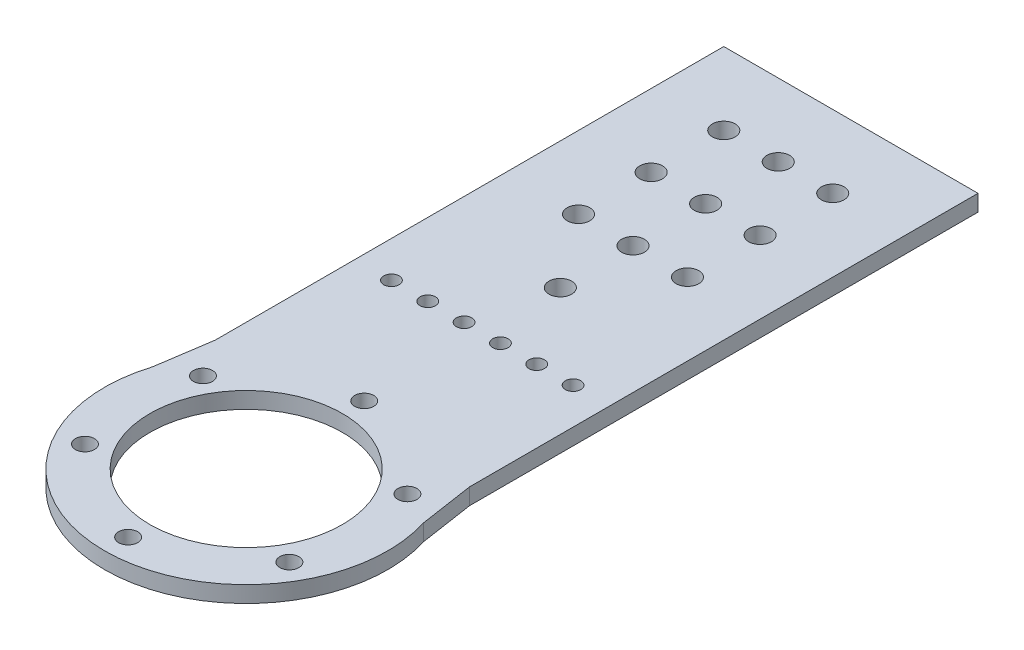
from build123d import *

# Parameters (mm, degrees)
SKETCH1_R               = 39
SKETCH1_R_2             = 26.5
BOSS_EXTRUDE1_DEPTH     = 2.25
SKETCH3_W               = 50
SKETCH3_H               = 51.5
BOSS_EXTRUDE2_DEPTH     = 2.25
BOSS_EXTRUDE4_DEPTH     = 2.25
SKETCH2_R               = 2.625
CUT_EXTRUDE1_DEPTH      = 3.25
CIRPATTERN1_COUNT       = 6
CUT_EXTRUDE3_START      = -5.5
SKETCH7_R               = 3.125
CUT_EXTRUDE3_DEPTH      = 6.5
LPATTERN3_COUNT         = 3
LPATTERN3_PITCH         = 20
SKETCH8_R               = 3.125
CUT_EXTRUDE4_DEPTH      = 10
LPATTERN4_COUNT         = 4
LPATTERN4_PITCH         = 20
CUT_EXTRUDE5_START      = -5.5
SKETCH9_R               = 2.125
CUT_EXTRUDE5_DEPTH      = 6.5
LPATTERN5_COUNT         = 3
LPATTERN5_PITCH         = 10
MIRROR1_START           = -5.5
MIRROR1_COPY_1_SKETCH_R = 2.125
MIRROR1_COPY_1_DEPTH    = 6.5
MIRROR1_COPY_2_SKETCH_R = 2.125
MIRROR1_COPY_2_DEPTH    = 6.5


with BuildPart() as part:
    # Sketch1 → Boss-Extrude1 (new body, symmetric)
    with BuildSketch(Plane(origin=(0, 0, 0), x_dir=(1, 0, 0), z_dir=(0, 1, 0))):
        Circle(SKETCH1_R)
        Circle(SKETCH1_R_2, mode=Mode.SUBTRACT)
    extrude(amount=BOSS_EXTRUDE1_DEPTH, both=True)

    # Sketch3 → Boss-Extrude2 (add, symmetric)
    with BuildSketch(Plane(origin=(0, 0, 0), x_dir=(1, 0, 0), z_dir=(0, 1, 0))):
        with Locations((0, 52.25)):
            Rectangle(SKETCH3_W, SKETCH3_H)
    extrude(amount=BOSS_EXTRUDE2_DEPTH, both=True)

    # Sketch6 → Boss-Extrude4 (add, symmetric)
    with BuildSketch(Plane(origin=(0, 0, 0), x_dir=(1, 0, 0), z_dir=(0, 1, 0))):
        Polygon((-35, 166.5), (-35, 26.5), (-39, 0), (-14.981514186, 26.5), (16.520833333, 26.5), (39, 0), (35, 26.5), (35, 166.5), align=None)
    extrude(amount=BOSS_EXTRUDE4_DEPTH, both=True)

    # Sketch2 → Cut-Extrude1 (cut, symmetric)
    with BuildSketch(Plane(origin=(0, 0, 0), x_dir=(1, 0, 0), z_dir=(0, 1, 0))):
        with Locations((0, 32.5)):
            Circle(SKETCH2_R)
    cut_extrude1 = extrude(amount=CUT_EXTRUDE1_DEPTH, both=True, mode=Mode.SUBTRACT)

    # CirPattern1: Cut-Extrude1 ×6 about axis
    cirpattern1_axis = Axis((0, 0, 0), (0, 1, 0))
    for i in range(1, CIRPATTERN1_COUNT):
        add(cut_extrude1.rotate(cirpattern1_axis, i * 360 / CIRPATTERN1_COUNT), mode=Mode.SUBTRACT)

    # Sketch7 → Cut-Extrude3 (cut)
    with BuildSketch(Plane(origin=(0, 2.25, 0), x_dir=(1, 0, 0), z_dir=(0, 1, 0)).offset(CUT_EXTRUDE3_START)):
        with Locations((-15, 146.5)):
            Circle(SKETCH7_R)
        with Locations((15, 146.5)):
            Circle(SKETCH7_R)
    cut_extrude3 = extrude(amount=CUT_EXTRUDE3_DEPTH, mode=Mode.SUBTRACT)

    # LPattern3: Cut-Extrude3 ×3
    with Locations(*[(0, 0, i * LPATTERN3_PITCH) for i in range(1, LPATTERN3_COUNT)]):
        add(cut_extrude3, mode=Mode.SUBTRACT)

    # Sketch8 → Cut-Extrude4 (cut)
    with BuildSketch(Plane(origin=(0, 2.25, 0), x_dir=(1, 0, 0), z_dir=(0, 1, 0))):
        with Locations((0, 146.5)):
            Circle(SKETCH8_R)
    cut_extrude4 = extrude(amount=-CUT_EXTRUDE4_DEPTH, mode=Mode.SUBTRACT)

    # LPattern4: Cut-Extrude4 ×4
    with Locations(*[(0, 0, i * LPATTERN4_PITCH) for i in range(1, LPATTERN4_COUNT)]):
        add(cut_extrude4, mode=Mode.SUBTRACT)

    # Sketch9 → Cut-Extrude5 (cut)
    with BuildSketch(Plane(origin=(0, 2.25, 0), x_dir=(1, 0, 0), z_dir=(0, 1, 0)).offset(CUT_EXTRUDE5_START)):
        with Locations((25, 65)):
            Circle(SKETCH9_R)
    cut_extrude5 = extrude(amount=CUT_EXTRUDE5_DEPTH, mode=Mode.SUBTRACT)

    # LPattern5: Cut-Extrude5 ×3
    with Locations(*[(-i * LPATTERN5_PITCH, 0, 0) for i in range(1, LPATTERN5_COUNT)]):
        add(cut_extrude5, mode=Mode.SUBTRACT)

    # Mirror1: Cut-Extrude5 across plane
    add(cut_extrude5.mirror(Plane(origin=(0, 0, 0), x_dir=(0, 0, 1), z_dir=(1, 0, 0))), mode=Mode.SUBTRACT)

    # Mirror1 copy 1 sketch → Mirror1 copy 1 (cut)
    with BuildSketch(Plane(origin=(10, 2.25, 0), x_dir=(-1, 0, 0), z_dir=(0, 1, 0)).offset(MIRROR1_START)):
        with Locations((25, -65)):
            Circle(MIRROR1_COPY_1_SKETCH_R)
    extrude(amount=MIRROR1_COPY_1_DEPTH, mode=Mode.SUBTRACT)

    # Mirror1 copy 2 sketch → Mirror1 copy 2 (cut)
    with BuildSketch(Plane(origin=(20, 2.25, 0), x_dir=(-1, 0, 0), z_dir=(0, 1, 0)).offset(MIRROR1_START)):
        with Locations((25, -65)):
            Circle(MIRROR1_COPY_2_SKETCH_R)
    extrude(amount=MIRROR1_COPY_2_DEPTH, mode=Mode.SUBTRACT)


solid = part.part
